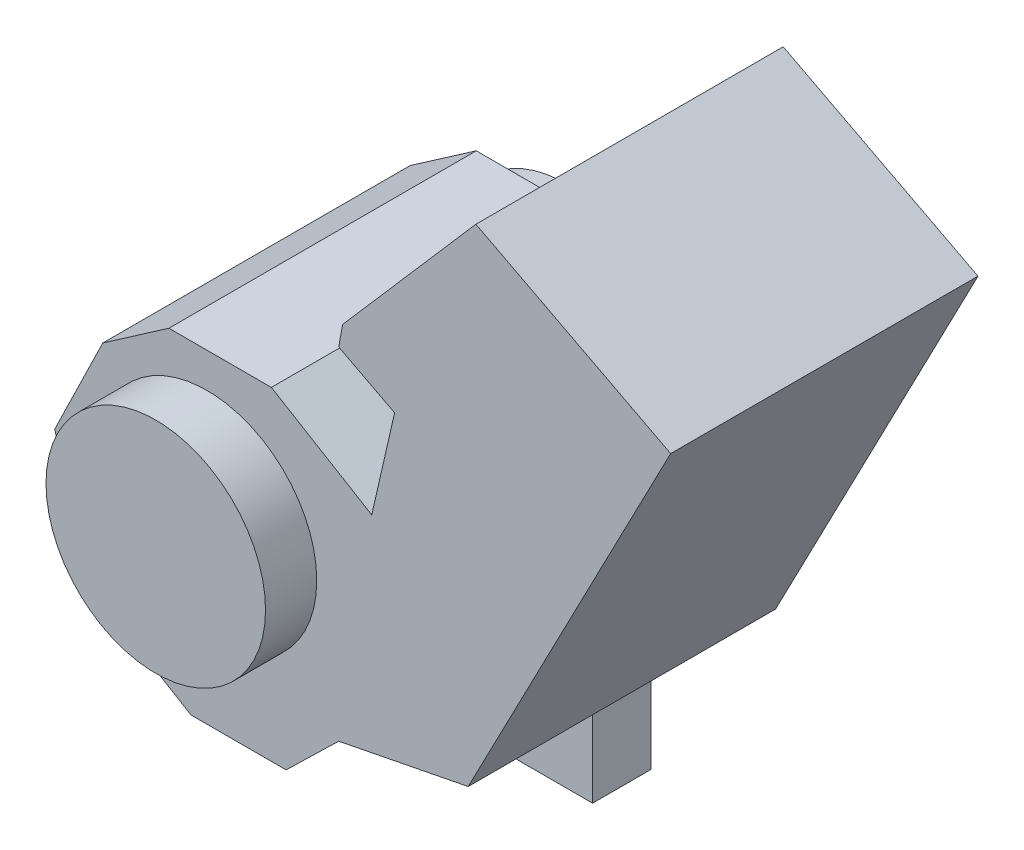
from build123d import *

# Parameters (mm, degrees)
BOSS_EXTRU_1_DEPTH      = 105
BOSS_EXTRU_1_DEPTH_BACK = 105
ESQUISSE1_R             = 75
BOSS_EXTRU_2_DEPTH      = 20
BOSS_EXTRU_2_DEPTH_BACK = 20
BOSS_EXTRU_3_DEPTH      = 140
BOSS_EXTRU_3_DEPTH_BACK = 140
ESQUISSE1_4_R           = 75


with BuildPart() as part:
    # Esquisse1 → Boss.-Extru.1 (new, two sides: drawn at the far end of the back side and taken through both)
    with BuildSketch(Plane.XY.offset(-BOSS_EXTRU_1_DEPTH_BACK)):
        Polygon((-68.596637727, 41.164320625), (0, 0), (65, 0), (100.963541268, 34.939277283), (189.435353132, 52.357657653), (327.774435506, 318.557391477), (194.674568594, 387.726932664), (103.646308232, 282.906907711), (100.963541268, 268.22841359), (139.16368684, 248.376503864), (123.528365835, 180.14501013), (54.931728108, 221.309330755), (-15.068271892, 221.309330755), (-60.266641359, 189.970737975), (-93.12076123, 122.549622532), align=None)
        with Locations((10.953732474, 122.549622532)):
            Circle(ESQUISSE1_R, mode=Mode.SUBTRACT)
    extrude(amount=BOSS_EXTRU_1_DEPTH + BOSS_EXTRU_1_DEPTH_BACK)

    # Esquisse1_3 → Boss.-Extru.2 (add, two sides: drawn at the far end of the back side and taken through both)
    with BuildSketch(Plane.XY.offset(-BOSS_EXTRU_2_DEPTH_BACK)):
        Polygon((100.963541268, 34.939277283), (65, 0), (189.435353132, 0), (189.435353132, 52.357657653), align=None)
    extrude(amount=BOSS_EXTRU_2_DEPTH + BOSS_EXTRU_2_DEPTH_BACK)

    # Esquisse1_4 → Boss.-Extru.3 (add, two sides: drawn at the far end of the back side and taken through both)
    with BuildSketch(Plane.XY.offset(-BOSS_EXTRU_3_DEPTH_BACK)):
        with Locations((10.953732474, 122.549622532)):
            Circle(ESQUISSE1_4_R)
    extrude(amount=BOSS_EXTRU_3_DEPTH + BOSS_EXTRU_3_DEPTH_BACK)


solid = part.part
